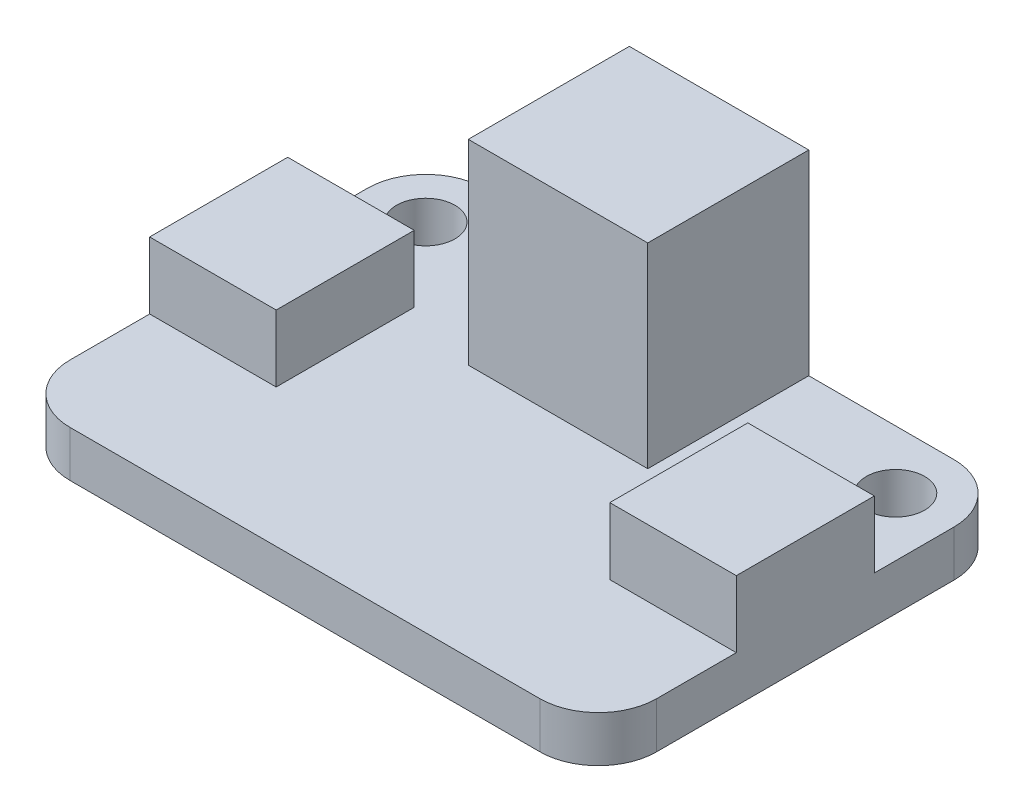
from build123d import *

# Parameters (mm, degrees)
SKETCH1_W           = 25.5
SKETCH1_H           = 18
BOSS_EXTRUDE1_DEPTH = 2
SKETCH2_R           = 1.27
CUT_EXTRUDE1_DEPTH  = 3
SKETCH3_W           = 5.5
SKETCH3_H           = 6
BOSS_EXTRUDE2_DEPTH = 2.9
SKETCH4_W           = 7.8
SKETCH4_H           = 7
BOSS_EXTRUDE3_DEPTH = 8.5
FILLET1_R           = 2.54


with BuildPart() as part:
    # Sketch1 → Boss-Extrude1 (new body)
    with BuildSketch(Plane(origin=(0, 0, 0), x_dir=(1, 0, 0), z_dir=(0, 1, 0))):
        with Locations((12.75, 9)):
            Rectangle(SKETCH1_W, SKETCH1_H)
    extrude(amount=BOSS_EXTRUDE1_DEPTH)

    # Sketch2 → Cut-Extrude1 (cut, through all)
    with BuildSketch(Plane(origin=(0, 2, 0), x_dir=(1, 0, 0), z_dir=(0, 1, 0))):
        with Locations((2.54, 15.46)):
            Circle(SKETCH2_R)
        with Locations((22.96, 15.46)):
            Circle(SKETCH2_R)
    extrude(amount=-CUT_EXTRUDE1_DEPTH, mode=Mode.SUBTRACT)

    # Sketch3 → Boss-Extrude2 (add)
    with BuildSketch(Plane(origin=(0, 2, 0), x_dir=(1, 0, 0), z_dir=(0, 1, 0))):
        with Locations((2.75, 9)):
            Rectangle(SKETCH3_W, SKETCH3_H)
        with Locations((22.75, 9)):
            Rectangle(SKETCH3_W, SKETCH3_H)
    extrude(amount=BOSS_EXTRUDE2_DEPTH)

    # Sketch4 → Boss-Extrude3 (add)
    with BuildSketch(Plane(origin=(0, 2, 0), x_dir=(1, 0, 0), z_dir=(0, 1, 0))):
        with Locations((12.75, 14.5)):
            Rectangle(SKETCH4_W, SKETCH4_H)
    extrude(amount=BOSS_EXTRUDE3_DEPTH)

    # Fillet1
    fillet1_edges = [part.edges().sort_by_distance(p)[0] for p in [
        (0, 1, -18),
        (25.5, 1, -18),
        (25.5, 1, 0),
        (0, 1, 0),
    ]]
    fillet(fillet1_edges, radius=FILLET1_R)


solid = part.part
